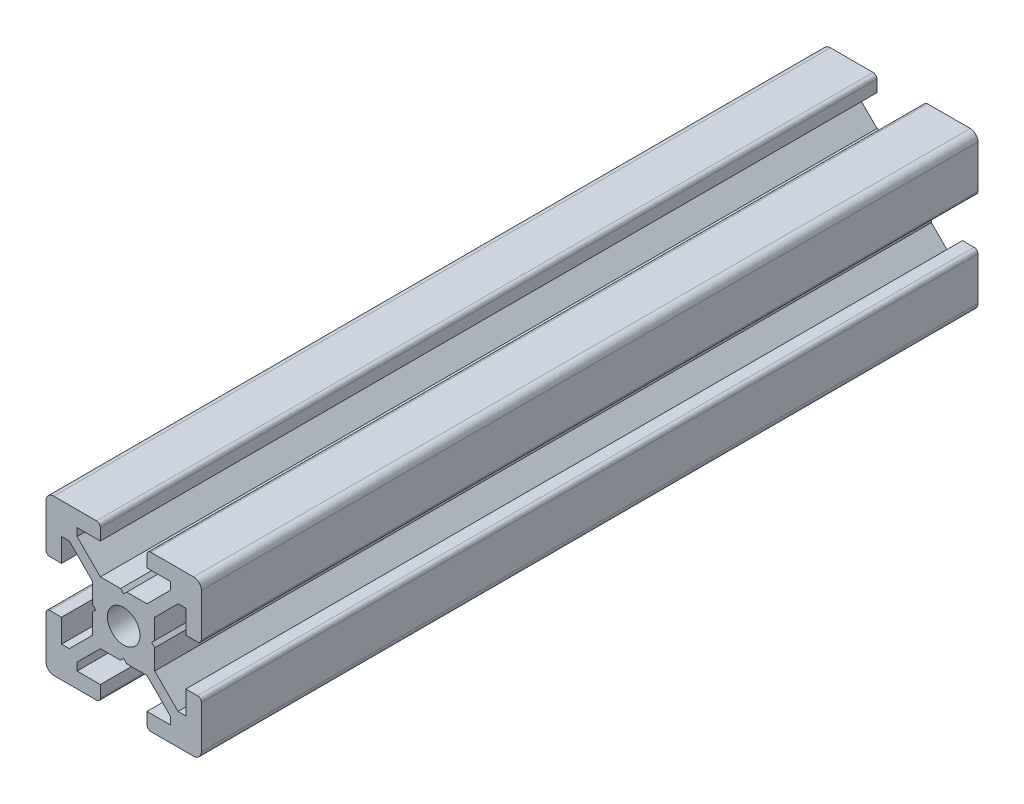
from build123d import *

# Parameters (mm, degrees)
SCHIZZO1_R                   = 2.1
ESTRUSIONE_ESTRUSIONE1_DEPTH = 100


with BuildPart() as part:
    # Schizzo1 → Estrusione-Estrusione1 (new body)
    with BuildSketch(Plane.XY):
        with BuildLine():
            Line((-3.6, 0), (-4, 0.4))
            Line((-4, 0.4), (-4, 3))
            Line((-4, 3), (-7, 6))
            Line((-7, 6), (-8, 6))
            Line((-8, 6), (-8, 3))
            Line((-8, 3), (-9.5, 3))
            ThreePointArc((-9.5, 3), (-9.853553391, 3.146446609), (-10, 3.5))
            Line((-10, 3.5), (-10, 9))
            ThreePointArc((-10, 9), (-9.707106781, 9.707106781), (-9, 10))
            Line((-9, 10), (-3.5, 10))
            ThreePointArc((-3.5, 10), (-3.146446609, 9.853553391), (-3, 9.5))
            Line((-3, 9.5), (-3, 8))
            Line((-3, 8), (-6, 8))
            Line((-6, 8), (-6, 7))
            Line((-6, 7), (-3, 4))
            Line((-3, 4), (-0.4, 4))
            Line((-0.4, 4), (0, 3.6))
            Line((0, 3.6), (0.4, 4))
            Line((0.4, 4), (3, 4))
            Line((3, 4), (6, 7))
            Line((6, 7), (6, 8))
            Line((6, 8), (3, 8))
            Line((3, 8), (3, 9.5))
            ThreePointArc((3, 9.5), (3.146446609, 9.853553391), (3.5, 10))
            Line((3.5, 10), (9, 10))
            ThreePointArc((9, 10), (9.707106781, 9.707106781), (10, 9))
            Line((10, 9), (10, 3.5))
            ThreePointArc((10, 3.5), (9.853553391, 3.146446609), (9.5, 3))
            Line((9.5, 3), (8, 3))
            Line((8, 3), (8, 6))
            Line((8, 6), (7, 6))
            Line((7, 6), (4, 3))
            Line((4, 3), (4, 0.4))
            Line((4, 0.4), (3.6, 0))
            Line((3.6, 0), (4, -0.4))
            Line((4, -0.4), (4, -3))
            Line((4, -3), (7, -6))
            Line((7, -6), (8, -6))
            Line((8, -6), (8, -3))
            Line((8, -3), (9.5, -3))
            ThreePointArc((9.5, -3), (9.853553391, -3.146446609), (10, -3.5))
            Line((10, -3.5), (10, -9))
            ThreePointArc((10, -9), (9.707106781, -9.707106781), (9, -10))
            Line((9, -10), (3.5, -10))
            ThreePointArc((3.5, -10), (3.146446609, -9.853553391), (3, -9.5))
            Line((3, -9.5), (3, -8))
            Line((3, -8), (6, -8))
            Line((6, -8), (6, -7))
            Line((6, -7), (3, -4))
            Line((3, -4), (0.4, -4))
            Line((0.4, -4), (0, -3.6))
            Line((0, -3.6), (-0.4, -4))
            Line((-0.4, -4), (-3, -4))
            Line((-3, -4), (-6, -7))
            Line((-6, -7), (-6, -8))
            Line((-6, -8), (-3, -8))
            Line((-3, -8), (-3, -9.5))
            ThreePointArc((-3, -9.5), (-3.146446609, -9.853553391), (-3.5, -10))
            Line((-3.5, -10), (-9, -10))
            ThreePointArc((-9, -10), (-9.707106781, -9.707106781), (-10, -9))
            Line((-10, -9), (-10, -3.5))
            ThreePointArc((-10, -3.5), (-9.853553391, -3.146446609), (-9.5, -3))
            Line((-9.5, -3), (-8, -3))
            Line((-8, -3), (-8, -6))
            Line((-8, -6), (-7, -6))
            Line((-7, -6), (-4, -3))
            Line((-4, -3), (-4, -0.4))
            Line((-4, -0.4), (-3.6, 0))
        make_face()
        Circle(SCHIZZO1_R, mode=Mode.SUBTRACT)
    extrude(amount=ESTRUSIONE_ESTRUSIONE1_DEPTH)


solid = part.part
